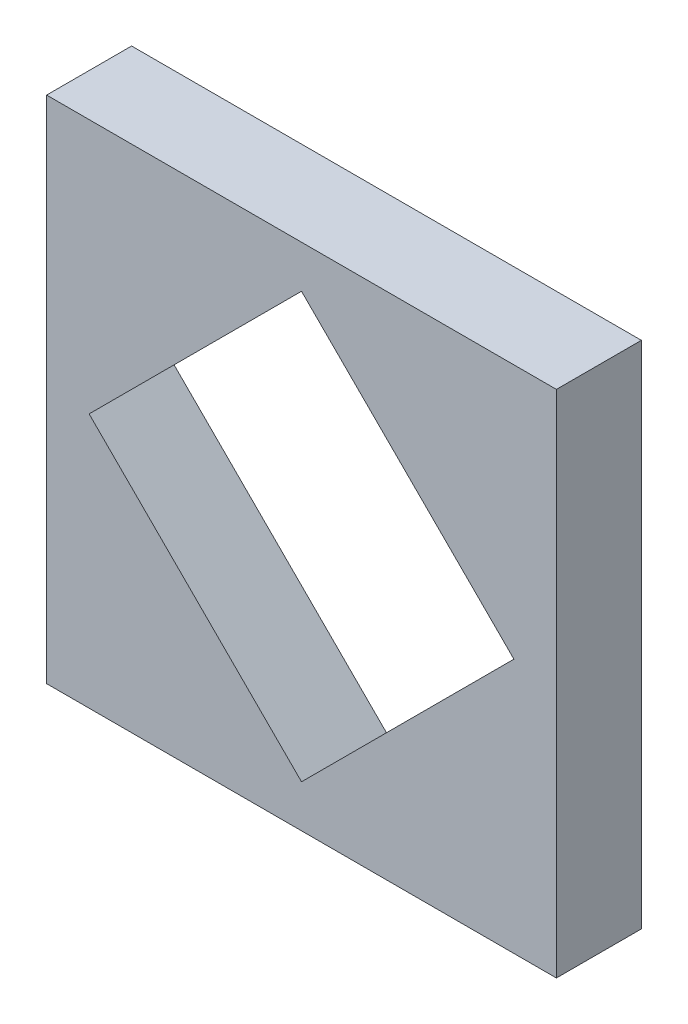
from build123d import *

# Parameters (mm, degrees)
SCHIZZO1_W                   = 60
SCHIZZO1_H                   = 60
ESTRUSIONE_ESTRUSIONE1_DEPTH = 10


with BuildPart() as part:
    # Schizzo1 → Estrusione-Estrusione1 (new body)
    with BuildSketch(Plane.XY):
        Rectangle(SCHIZZO1_W, SCHIZZO1_H)
        Polygon((0, -25), (25, 0), (0, 25), (-25, 0), align=None, mode=Mode.SUBTRACT)
    extrude(amount=ESTRUSIONE_ESTRUSIONE1_DEPTH)


solid = part.part
